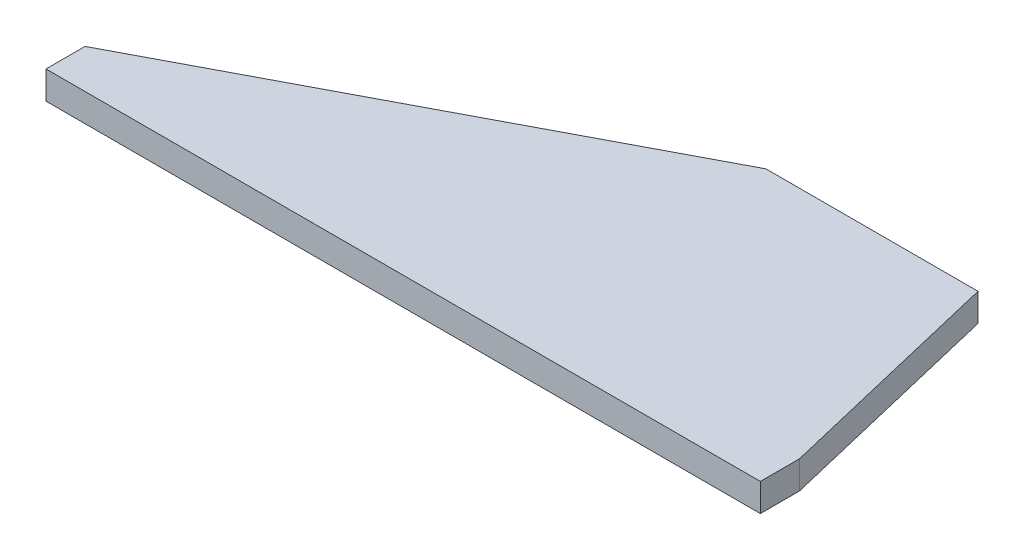
from build123d import *

# Parameters (mm, degrees)
BOSS_EXTRUDE1_DEPTH = 6.35


with BuildPart() as part:
    # Sketch1 → Boss-Extrude1 (new body)
    with BuildSketch(Plane(origin=(0, 0, 0), x_dir=(1, 0, 0), z_dir=(0, 1, 0))):
        Polygon((0, 0), (101.6, 53.34), (149.86, 53.34), (162.56, 0), (162.56, -8.89), (0, -8.89), align=None)
    extrude(amount=BOSS_EXTRUDE1_DEPTH)


solid = part.part
